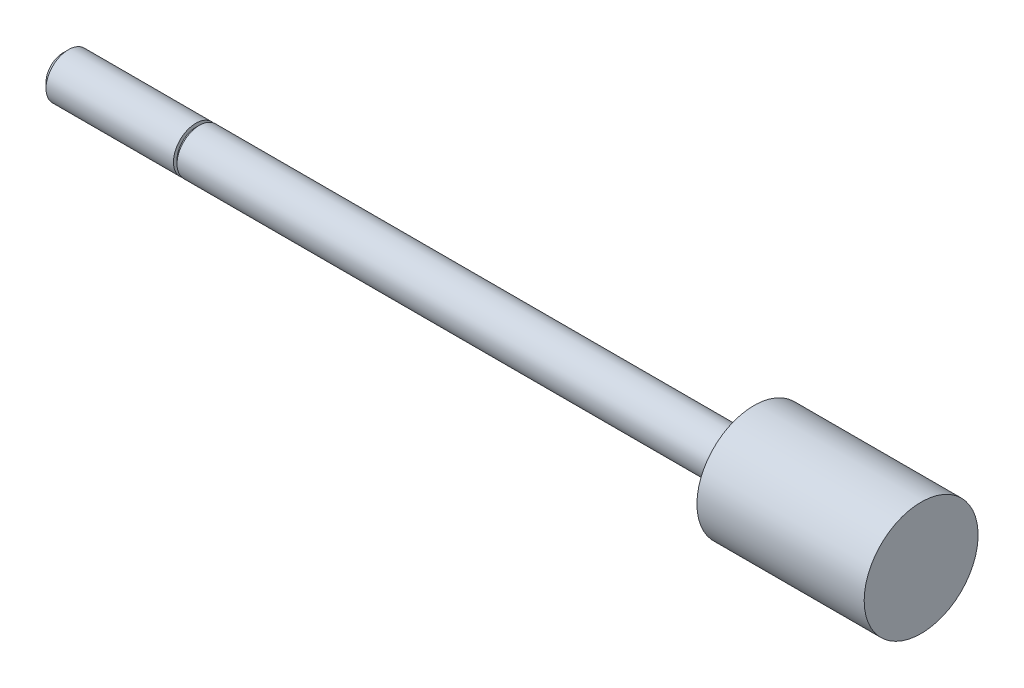
from build123d import *

# Parameters (mm, degrees)
SKETCH3_W = 0.254
SKETCH3_H = 0.508


with BuildPart() as part:
    # Sketch1 → Revolve1 (revolve)
    with BuildSketch(Plane.XY):
        Polygon((0, 0), (0, 1.5875), (39.243, 1.5875), (39.243, 4.03225), (51.0794, 4.03225), (51.0794, 0), align=None)
    revolve(axis=Axis((51.0794, 0, 0), (-1, 0, 0)))

    # Sketch2 → Revolve2 (revolve)
    with BuildSketch(Plane.XY):
        Polygon((-9.652, 0), (-9.652, 1.20904), (-9.27354, 1.5875), (0, 1.5875), (0, 0), align=None)
    revolve(axis=Axis((0, 0, 0), (-1, 0, 0)))

    # Sketch3 → Cut-Revolve1 (revolve, cut)
    with BuildSketch(Plane.XY):
        with Locations((-0.127, 1.5875)):
            Rectangle(SKETCH3_W, SKETCH3_H)
    revolve(axis=Axis((0, 0, 0), (-1, 0, 0)), mode=Mode.SUBTRACT)


solid = part.part
